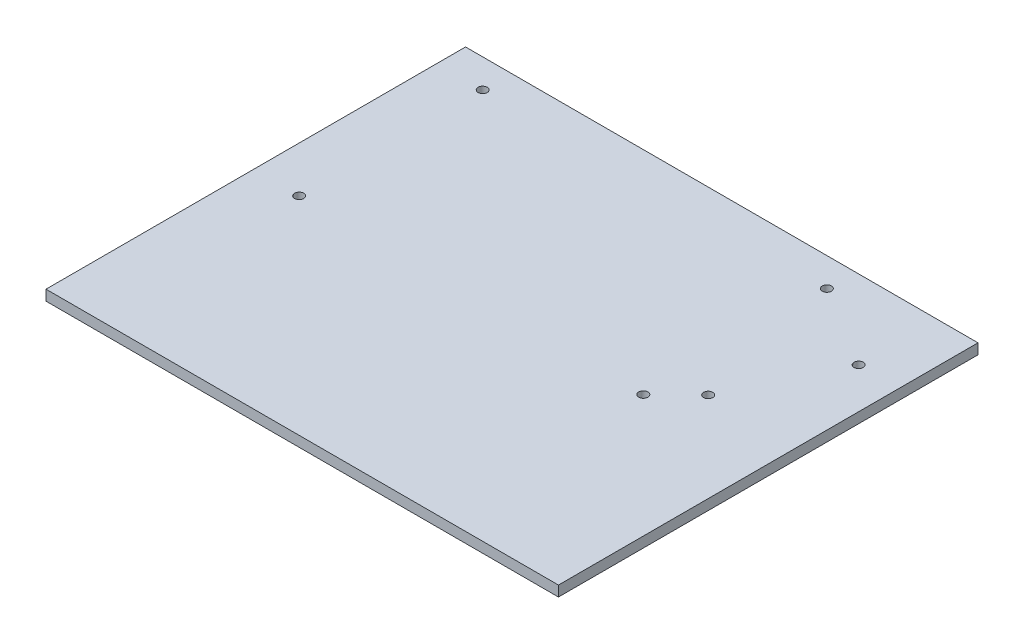
from build123d import *

# Parameters (mm, degrees)
SKETCH1_W           = 156.35
SKETCH1_H           = 128
BOSS_EXTRUDE1_DEPTH = 3.175
SKETCH2_R           = 1.4
CUT_EXTRUDE1_DEPTH  = 5


with BuildPart() as part:
    # Sketch1 → Boss-Extrude1 (new body)
    with BuildSketch(Plane(origin=(0, 0, 0), x_dir=(1, 0, 0), z_dir=(0, 1, 0))):
        with Locations((15.700078044, -66.928511967)):
            Rectangle(SKETCH1_W, SKETCH1_H)
    extrude(amount=BOSS_EXTRUDE1_DEPTH)

    # Sketch2 → Cut-Extrude1 (cut)
    with BuildSketch(Plane(origin=(0, 3.175, 0), x_dir=(1, 0, 0), z_dir=(0, 1, 0))):
        with Locations((56.489578195, -67.657956471)):
            Circle(SKETCH2_R)
        with Locations((66.489578195, -57.857956471)):
            Circle(SKETCH2_R)
        with Locations((81.489578195, -26.957956471)):
            Circle(SKETCH2_R)
        with Locations((56.489578195, -11.657956471)):
            Circle(SKETCH2_R)
        with Locations((-48.510421805, -11.657956471)):
            Circle(SKETCH2_R)
        with Locations((-48.510421805, -67.657956471)):
            Circle(SKETCH2_R)
    extrude(amount=-CUT_EXTRUDE1_DEPTH, mode=Mode.SUBTRACT)


solid = part.part
